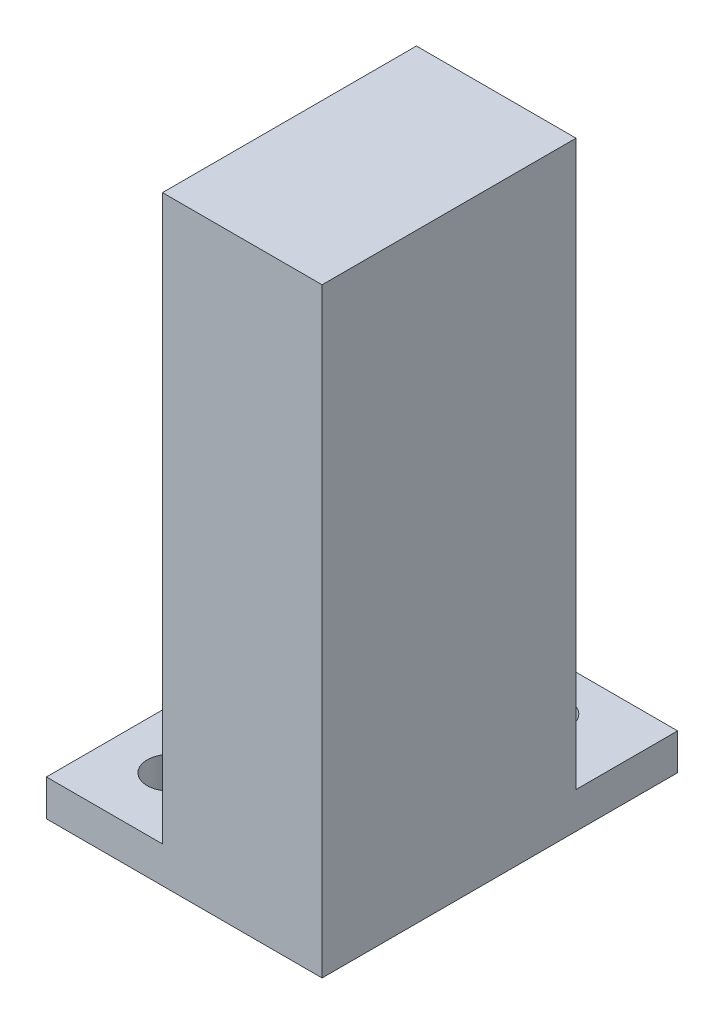
from build123d import *

# Parameters (mm, degrees)
SKETCH1_W           = 22
SKETCH1_H           = 82.75
SKETCH1_R           = 3.1
BOSS_EXTRUDE1_DEPTH = 30
SKETCH2_W           = 22
SKETCH2_H           = 82.75
BOSS_EXTRUDE2_DEPTH = 5
SKETCH3_W           = 16
SKETCH3_H           = 35
SKETCH3_R           = 3.1
SKETCH3_W_2         = 22
SKETCH3_H_2         = 14
BOSS_EXTRUDE3_DEPTH = 5


with BuildPart() as part:
    # Sketch1 → Boss-Extrude1 (new body)
    with BuildSketch(Plane.XY):
        with Locations((0, 7.844654309)):
            Rectangle(SKETCH1_W, SKETCH1_H)
        with Locations((0, 35.719654309)):
            Circle(SKETCH1_R, mode=Mode.SUBTRACT)
        with Locations((0, 7.719654309)):
            Circle(SKETCH1_R, mode=Mode.SUBTRACT)
    extrude(amount=BOSS_EXTRUDE1_DEPTH)

    # Sketch2 → Boss-Extrude2 (add)
    with BuildSketch(Plane.XY.offset(30)):
        with Locations((0, 7.844654309)):
            Rectangle(SKETCH2_W, SKETCH2_H)
    extrude(amount=BOSS_EXTRUDE2_DEPTH)

    # Sketch3 → Boss-Extrude3 (add)
    with BuildSketch(Plane.XZ.offset(33.530345691)):
        with Locations((-19, 17.5)):
            Rectangle(SKETCH3_W, SKETCH3_H)
        with Locations((-19, 26)):
            Circle(SKETCH3_R, mode=Mode.SUBTRACT)
        with Locations((-19, 9)):
            Circle(SKETCH3_R, mode=Mode.SUBTRACT)
        with Locations((0, -7)):
            Rectangle(SKETCH3_W_2, SKETCH3_H_2)
        with Locations((0, -7)):
            Circle(SKETCH3_R, mode=Mode.SUBTRACT)
    extrude(amount=-BOSS_EXTRUDE3_DEPTH)


solid = part.part
